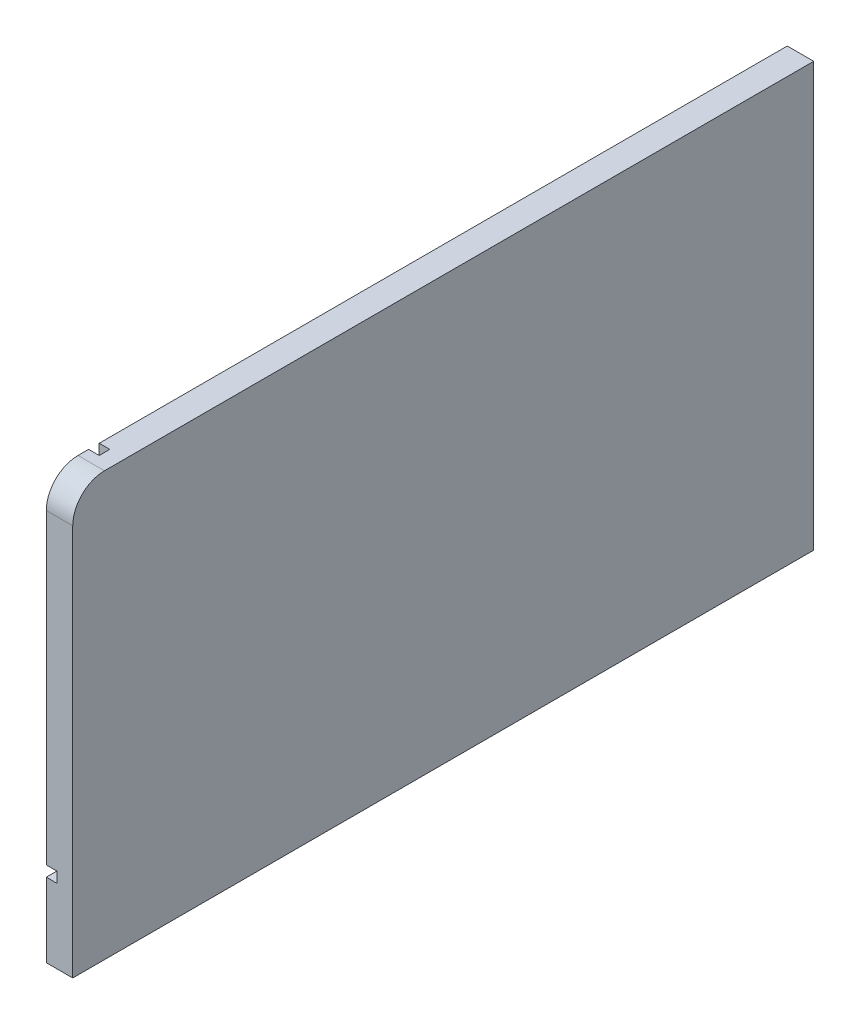
from build123d import *

# Parameters (mm, degrees)
BOSS_EXTRUDE1_DEPTH = 15.875
SKETCH2_W           = 6.35
SKETCH2_H           = 6.35
CUT_EXTRUDE1_DEPTH  = 445.5
CUT_EXTRUDE2_REACH  = 256
SKETCH3_W           = 6.35
SKETCH3_H           = 6.35
CUT_EXTRUDE3_REACH  = 256
SKETCH4_W           = 6.35
SKETCH4_H           = 6.35


with BuildPart() as part:
    # Sketch1 → Boss-Extrude1 (new body)
    with BuildSketch(Plane(origin=(0, 0, 0), x_dir=(0, 0, -1), z_dir=(1, 0, 0))):
        with BuildLine():
            Line((0, 0), (444.5, 0))
            Line((444.5, 0), (444.5, 254))
            Line((444.5, 254), (19.05, 254))
            ThreePointArc((19.05, 254), (5.579615818, 248.420384182), (0, 234.95))
            Line((0, 234.95), (0, 0))
        make_face()
    extrude(amount=BOSS_EXTRUDE1_DEPTH)

    # Sketch2 → Cut-Extrude1 (cut, through all)
    with BuildSketch(Plane(origin=(0, 0, -444.5), x_dir=(-1, 0, 0), z_dir=(0, 0, -1))):
        with Locations((-3.175, 47.625)):
            Rectangle(SKETCH2_W, SKETCH2_H)
    extrude(amount=-CUT_EXTRUDE1_DEPTH, mode=Mode.SUBTRACT)

    # Sketch3 → Cut-Extrude2 (cut, up to next)
    with BuildSketch(Plane.XZ, mode=Mode.PRIVATE) as cut_extrude2_sk1:
        with Locations((3.175, -9.525)):
            Rectangle(SKETCH3_W, SKETCH3_H)
    cut_extrude2_tool1 = extrude(cut_extrude2_sk1.sketch, amount=-CUT_EXTRUDE2_REACH, mode=Mode.PRIVATE) & part.part
    add(cut_extrude2_tool1.solids().sort_by_distance((3.175, 0, -9.525))[0], mode=Mode.SUBTRACT)

    # Sketch4 → Cut-Extrude3 (cut, up to next)
    with BuildSketch(Plane(origin=(0, 254, 0), x_dir=(1, 0, 0), z_dir=(0, 1, 0)), mode=Mode.PRIVATE) as cut_extrude3_sk1:
        with Locations((3.175, 28.575)):
            Rectangle(SKETCH4_W, SKETCH4_H)
    cut_extrude3_tool1 = extrude(cut_extrude3_sk1.sketch, amount=-CUT_EXTRUDE3_REACH, mode=Mode.PRIVATE) & part.part
    add(cut_extrude3_tool1.solids().sort_by_distance((3.175, 254, -28.575))[0], mode=Mode.SUBTRACT)


solid = part.part
